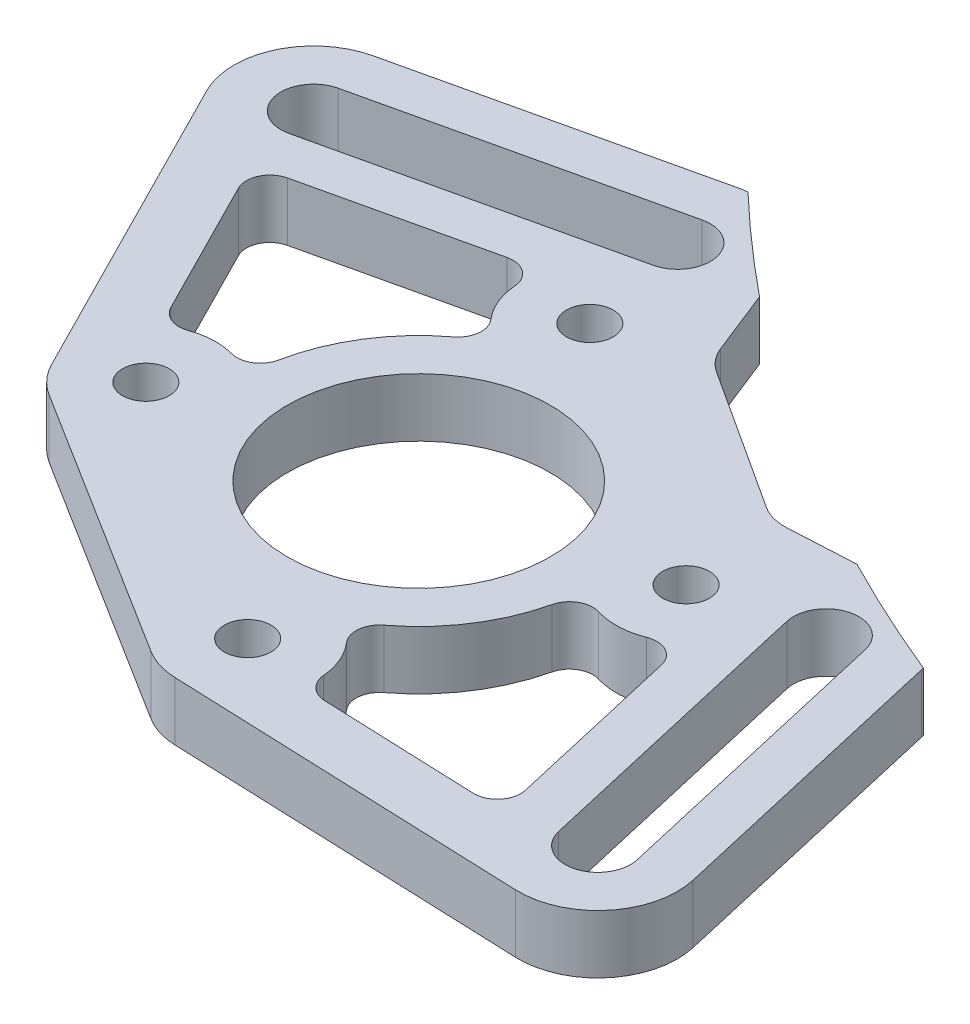
from build123d import *

# Parameters (mm, degrees)
SKETCH1_R           = 2.54
SKETCH1_R_2         = 14.2875
BOSS_EXTRUDE1_DEPTH = 6.35
SKETCH3_R           = 175
CUT_EXTRUDE1_DEPTH  = 7.35
FILLET1_R           = 2.54


with BuildPart() as part:
    # Sketch1 → Boss-Extrude1 (new body)
    with BuildSketch(Plane(origin=(0, 0, 0), x_dir=(1, 0, 0), z_dir=(0, 1, 0))):
        with BuildLine():
            Line((-10.301536111, 44.922263418), (-42.486128255, 37.541719497))
            ThreePointArc((-42.486128255, 37.541719497), (-48.376257791, 32.787738977), (-48.258608454, 25.219376184))
            Line((-48.258608454, 25.219376184), (-30.922632743, -8.978011563))
            ThreePointArc((-30.922632743, -8.978011563), (-29.753188396, -10.670651305), (-28.173552503, -11.988748349))
            Line((-28.173552503, -11.988748349), (1.485082186, -30.582244497))
            ThreePointArc((1.485082186, -30.582244497), (3.286793362, -31.407609936), (5.240405543, -31.740462332))
            Line((5.240405543, -31.740462332), (43.718670442, -33.216869907))
            ThreePointArc((43.718670442, -33.216869907), (50.700017874, -30.096753296), (52.467298047, -22.656923969))
            Line((52.467298047, -22.656923969), (45.086754126, 9.527668174))
            ThreePointArc((45.086754126, 9.527668174), (41.870070274, 14.491711544), (36.213465331, 16.221336388))
            Line((36.213465331, 16.221336388), (24.402688291, 15.597131936))
            ThreePointArc((24.402688291, 15.597131936), (22.820864626, 15.76285886), (21.367816063, 16.409605637))
            Line((21.367816063, 16.409605637), (5.906875614, 26.450057762))
            ThreePointArc((5.906875614, 26.450057762), (4.742385284, 27.493110687), (3.950204921, 28.84086712))
            Line((3.950204921, 28.84086712), (-0.341397124, 39.683137821))
            ThreePointArc((-0.341397124, 39.683137821), (-4.350888408, 44.147873767), (-10.301536111, 44.922263418))
        make_face()
        with Locations((-5.53256927, 24.126065418)):
            Circle(SKETCH1_R, mode=Mode.SUBTRACT)
        with Locations((24.290556126, 4.758701333)):
            Circle(SKETCH1_R, mode=Mode.SUBTRACT)
        with Locations((5.53256927, -24.126065418)):
            Circle(SKETCH1_R, mode=Mode.SUBTRACT)
        with Locations((-24.126065418, -5.53256927)):
            Circle(SKETCH1_R, mode=Mode.SUBTRACT)
        Circle(SKETCH1_R_2, mode=Mode.SUBTRACT)
        with BuildLine():
            Line((40.135278412, 8.392199879), (47.515822333, -23.792392264))
            ThreePointArc((47.515822333, -23.792392264), (44.84461714, -28.053253071), (40.583756333, -25.382047878))
            Line((40.583756333, -25.382047878), (33.203212412, 6.802544265))
            ThreePointArc((33.203212412, 6.802544265), (35.874417605, 11.063405072), (40.135278412, 8.392199879))
        make_face(mode=Mode.SUBTRACT)
        with BuildLine():
            Line((-7.576412202, 33.038721704), (-39.761004345, 25.658177783))
            ThreePointArc((-39.761004345, 25.658177783), (-44.021865152, 28.329382976), (-41.350659959, 32.590243783))
            Line((-41.350659959, 32.590243783), (-9.166067816, 39.970787704))
            ThreePointArc((-9.166067816, 39.970787704), (-4.905207009, 37.299582511), (-7.576412202, 33.038721704))
        make_face(mode=Mode.SUBTRACT)
    extrude(amount=BOSS_EXTRUDE1_DEPTH)

    # Sketch3 → Cut-Extrude1 (cut, through all)
    with BuildSketch(Plane(origin=(0, 6.35, 0), x_dir=(1, 0, 0), z_dir=(0, 1, 0))):
        with Locations((111.500681804, 171.695993352)):
            Circle(SKETCH3_R)
        with BuildLine():
            Line((29.692484449, -0.615642385), (35.632280619, -26.517516174))
            ThreePointArc((35.632280619, -26.517516174), (35.636280873, -26.534877998), (35.640316938, -26.552231532))
            Line((35.640316938, -26.552231532), (12.991771922, -25.68320889))
            ThreePointArc((12.991771922, -25.68320889), (12.360044144, -20.742282498), (8.810828705, -17.247299898))
            ThreePointArc((8.810828705, -17.247299898), (16.242952225, -10.548296511), (19.339879369, -1.033983679))
            ThreePointArc((19.339879369, -1.033983679), (24.598223728, -2.85508489), (29.692484449, -0.615642385))
        make_face()
        with BuildLine():
            Line((-38.62553605, 20.706702069), (-12.723662261, 26.646498238))
            ThreePointArc((-12.723662261, 26.646498238), (-12.567344847, 21.197527799), (-8.810828705, 17.247299898))
            ThreePointArc((-8.810828705, 17.247299898), (-16.40945516, 10.287363006), (-19.363045216, 0.415374791))
            ThreePointArc((-19.363045216, 0.415374791), (-23.979054852, 2.086012481), (-28.656078555, 0.594696105))
            Line((-28.656078555, 0.594696105), (-38.829256345, 20.662566027))
            ThreePointArc((-38.829256345, 20.662566027), (-38.727263029, 20.684019377), (-38.62553605, 20.706702069))
        make_face()
    extrude(amount=-CUT_EXTRUDE1_DEPTH, mode=Mode.SUBTRACT)

    # Fillet1
    fillet1_edges = [part.edges().sort_by_distance(p)[0] for p in [
        (35.640316938, 3.175, 26.552231532),
        (8.810828705, 3.175, 17.247299898),
        (12.991771922, 3.175, 25.68320889),
        (29.692484449, 3.175, 0.615642385),
        (19.339879369, 3.175, 1.033983679),
        (-38.829256345, 3.175, -20.662566027),
        (-28.656078555, 3.175, -0.594696105),
        (-19.363045216, 3.175, -0.415374791),
        (-8.810828705, 3.175, -17.247299898),
        (-12.723662261, 3.175, -26.646498238),
    ]]
    fillet(fillet1_edges, radius=FILLET1_R)


solid = part.part
